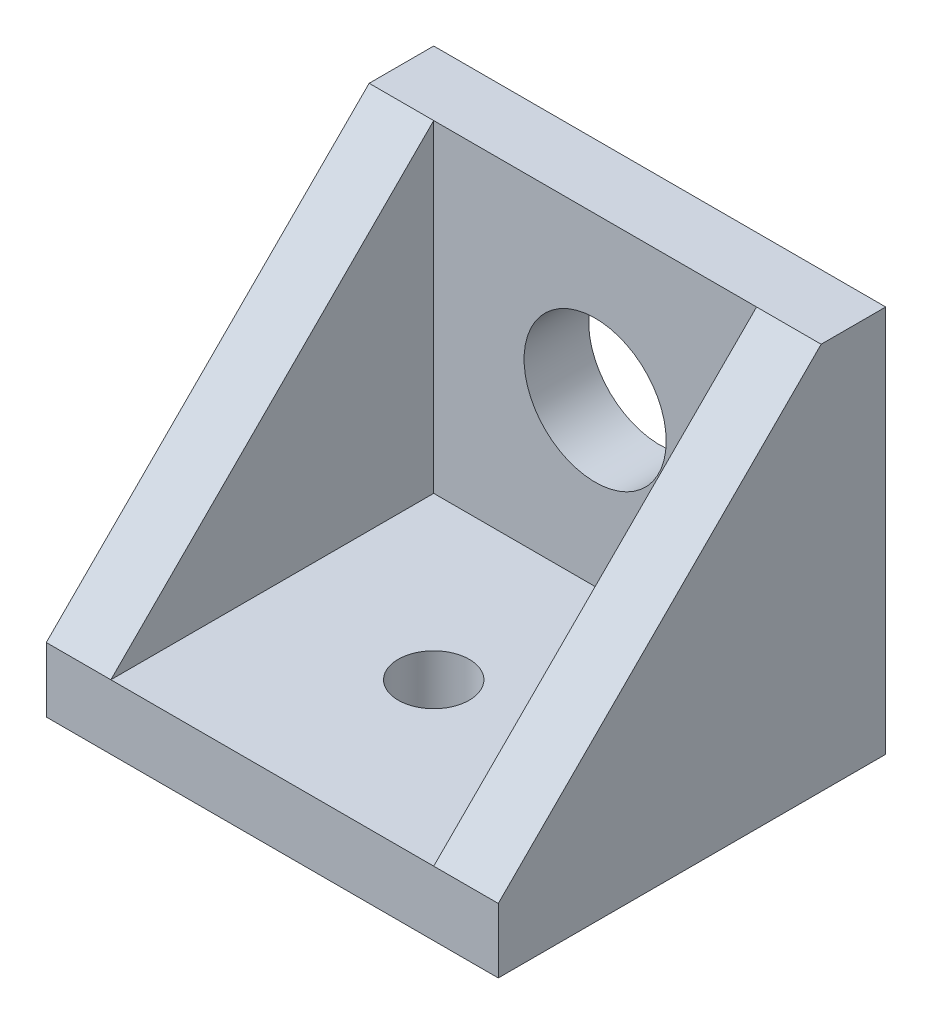
from build123d import *

# Parameters (mm, degrees)
SKETCH1_W           = 15
SKETCH1_H           = 15
SKETCH1_R           = 3.302
BOSS_EXTRUDE1_DEPTH = 3
SKETCH2_W           = 15
SKETCH2_H           = 18
SKETCH2_R           = 1.65
BOSS_EXTRUDE2_DEPTH = 3
BOSS_EXTRUDE3_DEPTH = 3


with BuildPart() as part:
    # Sketch1 → Boss-Extrude1 (new body)
    with BuildSketch(Plane.XY):
        Rectangle(SKETCH1_W, SKETCH1_H)
        Circle(SKETCH1_R, mode=Mode.SUBTRACT)
    extrude(amount=BOSS_EXTRUDE1_DEPTH)

    # Sketch2 → Boss-Extrude2 (add)
    with BuildSketch(Plane.XZ.offset(7.5)):
        with Locations((0, 9)):
            Rectangle(SKETCH2_W, SKETCH2_H)
        with Locations((0, 10.5)):
            Circle(SKETCH2_R, mode=Mode.SUBTRACT)
    extrude(amount=BOSS_EXTRUDE2_DEPTH)

    # Sketch3 → Boss-Extrude3 (add)
    with BuildSketch(Plane(origin=(7.5, 0, 0), x_dir=(0, 0, -1), z_dir=(1, 0, 0))):
        Polygon((-18, -10.5), (-18, -7.5), (-3, 7.5), (0, 7.5), (0, -10.5), align=None)
    boss_extrude3 = extrude(amount=BOSS_EXTRUDE3_DEPTH)

    # Mirror1: Boss-Extrude3 across plane
    add(boss_extrude3.mirror(Plane(origin=(0, 0, 0), x_dir=(0, 0, 1), z_dir=(1, 0, 0))))


solid = part.part
